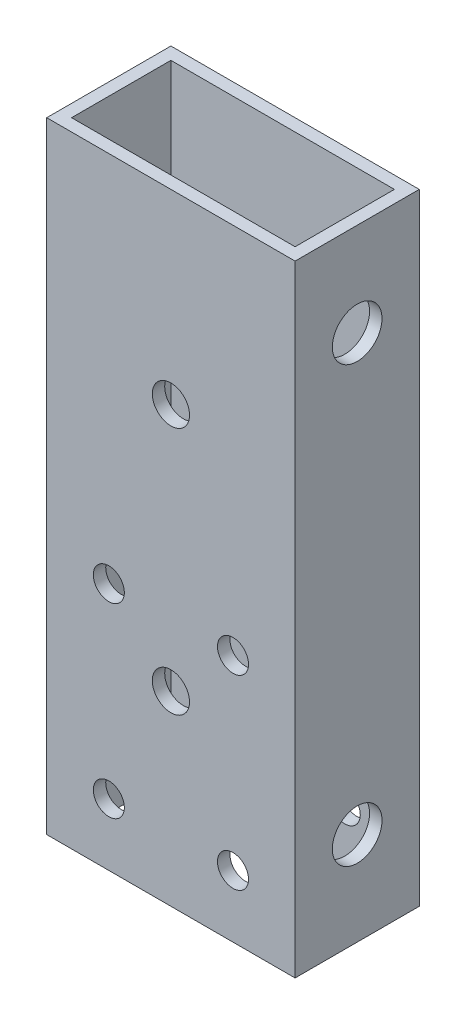
from build123d import *

# Parameters (mm, degrees)
SKICA1_W                 = 40
SKICA1_H                 = 20
SKICA1_W_2               = 36
SKICA1_H_2               = 16
P_IDAT_VYSUNUT_M1_DEPTH  = 100
SKICA2_R                 = 4
ODEBRAT_VYSUNUT_M1_DEPTH = 40
SKETCH1_R                = 2.5
CUT_EXTRUDE1_DEPTH       = 20
SKETCH2_R                = 3
CUT_EXTRUDE2_DEPTH       = 2


with BuildPart() as part:
    # Skica1 → Přidat vysunutím1 (new body)
    with BuildSketch(Plane(origin=(0, 0, 0), x_dir=(1, 0, 0), z_dir=(0, 1, 0))):
        with Locations((20, 10)):
            Rectangle(SKICA1_W, SKICA1_H)
        with Locations((20, 10)):
            Rectangle(SKICA1_W_2, SKICA1_H_2, mode=Mode.SUBTRACT)
    extrude(amount=P_IDAT_VYSUNUT_M1_DEPTH)

    # Skica2 → Odebrat vysunutím1 (cut)
    with BuildSketch(Plane(origin=(40, 0, 0), x_dir=(0, 0, -1), z_dir=(1, 0, 0))):
        with Locations((10, 85)):
            Circle(SKICA2_R)
        with Locations((10, 15)):
            Circle(SKICA2_R)
    extrude(amount=-ODEBRAT_VYSUNUT_M1_DEPTH, mode=Mode.SUBTRACT)

    # Sketch1 → Cut-Extrude1 (cut)
    with BuildSketch(Plane.XY):
        with Locations((10, 10)):
            Circle(SKETCH1_R)
        with Locations((30, 10)):
            Circle(SKETCH1_R)
        with Locations((30, 40)):
            Circle(SKETCH1_R)
        with Locations((10, 40)):
            Circle(SKETCH1_R)
    extrude(amount=-CUT_EXTRUDE1_DEPTH, mode=Mode.SUBTRACT)

    # Sketch2 → Cut-Extrude2 (cut)
    with BuildSketch(Plane.XY):
        with Locations((20, 30)):
            Circle(SKETCH2_R)
        with Locations((20, 70)):
            Circle(SKETCH2_R)
    extrude(amount=-CUT_EXTRUDE2_DEPTH, mode=Mode.SUBTRACT)


solid = part.part
